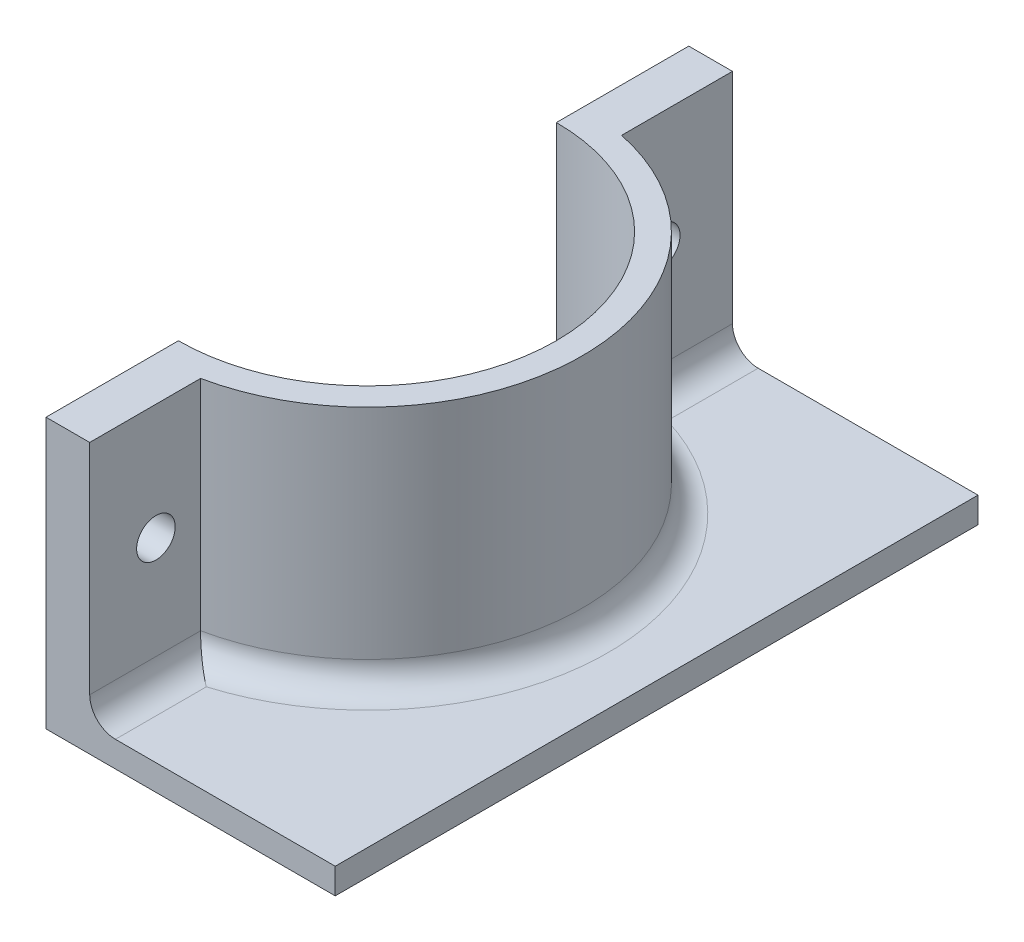
from build123d import *

# Parameters (mm, degrees)
BOSS_EXTRUDE12_DEPTH    = 26.67
BOSS_EXTRUDE13_DEPTH    = 2.54
FILLET2_R               = 2.54
SKETCH5_R               = 1.905
CUT_EXTRUDE1_DEPTH      = 58.15
CUT_EXTRUDE1_DEPTH_BACK = 1


with BuildPart() as part:
    # Sketch3 → Boss-Extrude12 (new body)
    with BuildSketch(Plane(origin=(0, 0, 0), x_dir=(1, 0, 0), z_dir=(0, 1, 0))):
        with BuildLine():
            Line((28.575, 13.081), (28.575, 0))
            Line((28.575, 0), (32.893, 0))
            Line((32.893, 0), (32.893, 10.953386454))
            ThreePointArc((32.893, 10.953386454), (49.815156756, 31.75), (32.893, 52.546613546))
            Line((32.893, 52.546613546), (32.893, 63.5))
            Line((32.893, 63.5), (28.575, 63.5))
            Line((28.575, 63.5), (28.575, 50.419))
            ThreePointArc((28.575, 50.419), (41.775976498, 44.950976498), (47.244, 31.75))
            ThreePointArc((47.244, 31.75), (41.775976498, 18.549023502), (28.575, 13.081))
        make_face()
    extrude(amount=BOSS_EXTRUDE12_DEPTH)

    # Sketch3_16 → Boss-Extrude13 (add)
    with BuildSketch(Plane(origin=(0, 0, 0), x_dir=(1, 0, 0), z_dir=(0, 1, 0))):
        with BuildLine():
            Line((32.893, 10.953386454), (32.893, 0))
            Line((32.893, 0), (57.15, 0))
            Line((57.15, 0), (57.15, 63.5))
            Line((57.15, 63.5), (32.893, 63.5))
            Line((32.893, 63.5), (32.893, 52.546613546))
            ThreePointArc((32.893, 52.546613546), (49.815156756, 31.75), (32.893, 10.953386454))
        make_face()
    extrude(amount=BOSS_EXTRUDE13_DEPTH)

    # Fillet2
    fillet2_edges = [part.edges().sort_by_distance(p)[0] for p in [
        (49.815156756, 2.54, -31.75),
        (32.893, 2.54, -5.476693227),
        (32.893, 2.54, -58.023306773),
    ]]
    fillet(fillet2_edges, radius=FILLET2_R)

    # Sketch5 → Cut-Extrude1 (cut, two sides)
    with BuildSketch(Plane(origin=(0, 0, 0), x_dir=(0, 0, -1), z_dir=(1, 0, 0))) as cut_extrude1_sk:
        with Locations((6.5405, 15.24)):
            Circle(SKETCH5_R)
        with Locations((56.41762459, 15.24)):
            Circle(SKETCH5_R)
    extrude(amount=CUT_EXTRUDE1_DEPTH, mode=Mode.SUBTRACT)
    extrude(cut_extrude1_sk.sketch, amount=-CUT_EXTRUDE1_DEPTH_BACK, mode=Mode.SUBTRACT)


solid = part.part
